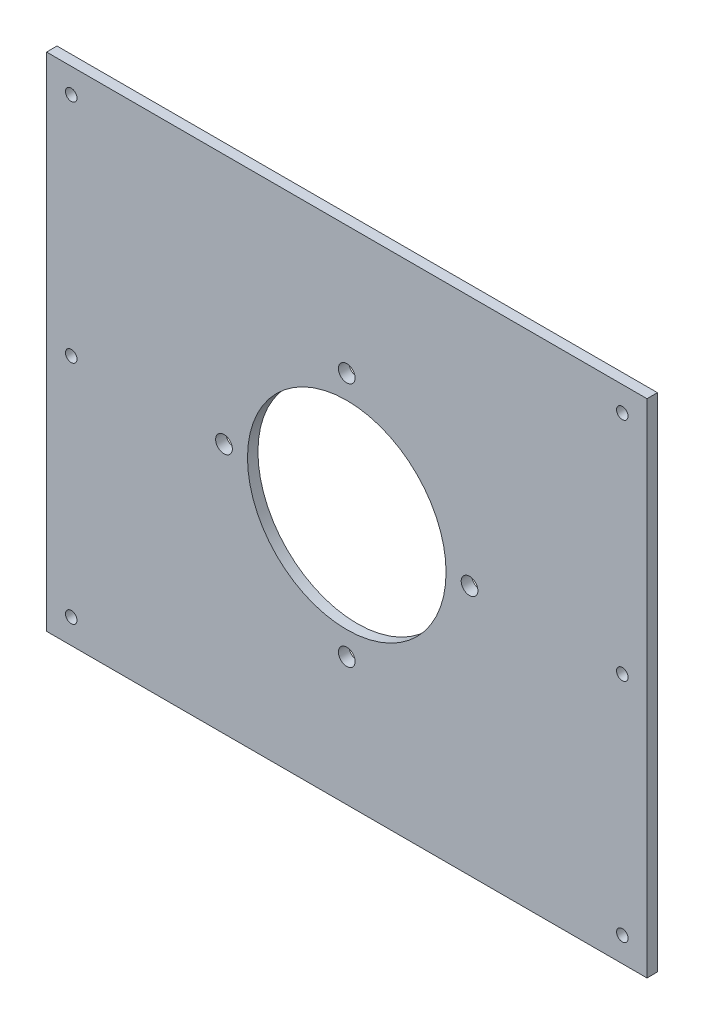
from build123d import *

# Parameters (mm, degrees)
SKETCH1_W           = 364.8
SKETCH1_H           = 304.8
SKETCH1_R           = 60.325
SKETCH1_R_2         = 5.08
SKETCH1_R_3         = 3.5
BOSS_EXTRUDE1_DEPTH = 6.35


with BuildPart() as part:
    # Sketch1 → Boss-Extrude1 (new body)
    with BuildSketch(Plane.XY):
        with Locations((102.199217301, 57.89924129)):
            Rectangle(SKETCH1_W, SKETCH1_H)
        with Locations((102.199217301, 57.89924129)):
            Circle(SKETCH1_R, mode=Mode.SUBTRACT)
        with Locations((102.199217301, 132.499241315)):
            Circle(SKETCH1_R_2, mode=Mode.SUBTRACT)
        with Locations((27.599217276, 57.89924129)):
            Circle(SKETCH1_R_2, mode=Mode.SUBTRACT)
        with Locations((102.199217301, -16.700758735)):
            Circle(SKETCH1_R_2, mode=Mode.SUBTRACT)
        with Locations((176.799217326, 57.89924129)):
            Circle(SKETCH1_R_2, mode=Mode.SUBTRACT)
        with Locations((-65.200782699, 195.29924129)):
            Circle(SKETCH1_R_3, mode=Mode.SUBTRACT)
        with Locations((-65.200782699, 57.89924129)):
            Circle(SKETCH1_R_3, mode=Mode.SUBTRACT)
        with Locations((-65.200782699, -79.50075871)):
            Circle(SKETCH1_R_3, mode=Mode.SUBTRACT)
        with Locations((269.599217301, 195.29924129)):
            Circle(SKETCH1_R_3, mode=Mode.SUBTRACT)
        with Locations((269.599217301, 57.89924129)):
            Circle(SKETCH1_R_3, mode=Mode.SUBTRACT)
        with Locations((269.599217301, -79.50075871)):
            Circle(SKETCH1_R_3, mode=Mode.SUBTRACT)
    extrude(amount=BOSS_EXTRUDE1_DEPTH)


solid = part.part
